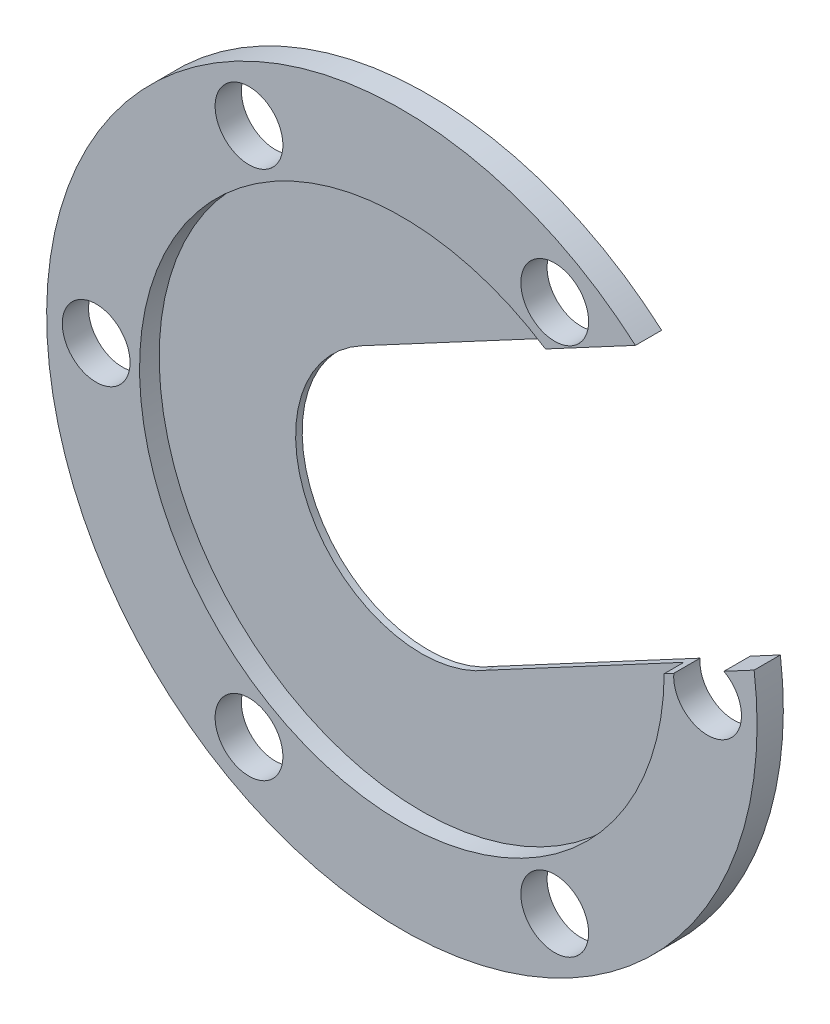
from build123d import *

# Parameters (mm, degrees)
SKETCH2_R           = 42.9895
SKETCH2_R_2         = 4.1021
SKETCH2_R_3         = 15.24
BOSS_EXTRUDE2_DEPTH = 3.175
SKETCH3_R           = 31.75
CUT_EXTRUDE1_DEPTH  = 2.38125
CUT_EXTRUDE2_DEPTH  = 4.1275


with BuildPart() as part:
    # Sketch2 → Boss-Extrude2 (new body)
    with BuildSketch(Plane.XY):
        with Locations((-4e-09, 0)):
            Circle(SKETCH2_R)
        with Locations((-18.49755, 32.038696425)):
            Circle(SKETCH2_R_2, mode=Mode.SUBTRACT)
        with Locations((18.49755, 32.038696425)):
            Circle(SKETCH2_R_2, mode=Mode.SUBTRACT)
        with Locations((36.9951, 0)):
            Circle(SKETCH2_R_2, mode=Mode.SUBTRACT)
        with Locations((18.49755, -32.038696425)):
            Circle(SKETCH2_R_2, mode=Mode.SUBTRACT)
        with Locations((-18.49755, -32.038696425)):
            Circle(SKETCH2_R_2, mode=Mode.SUBTRACT)
        with Locations((-36.9951, 0)):
            Circle(SKETCH2_R_2, mode=Mode.SUBTRACT)
        with Locations((-4e-09, 0)):
            Circle(SKETCH2_R_3, mode=Mode.SUBTRACT)
    extrude(amount=BOSS_EXTRUDE2_DEPTH)

    # Sketch3 → Cut-Extrude1 (cut)
    with BuildSketch(Plane.XY.offset(3.175)):
        with Locations((-4e-09, 0)):
            Circle(SKETCH3_R)
    extrude(amount=-CUT_EXTRUDE1_DEPTH, mode=Mode.SUBTRACT)

    # Sketch3_3 → Cut-Extrude2 (cut)
    with BuildSketch(Plane.XY.offset(3.175)):
        Polygon((-7.185170954, 13.439900239), (37.844396615, 37.513378093), (51.563249181, 10.3209669), (6.307069446, -13.873661195), align=None)
    extrude(amount=-CUT_EXTRUDE2_DEPTH, mode=Mode.SUBTRACT)


solid = part.part
